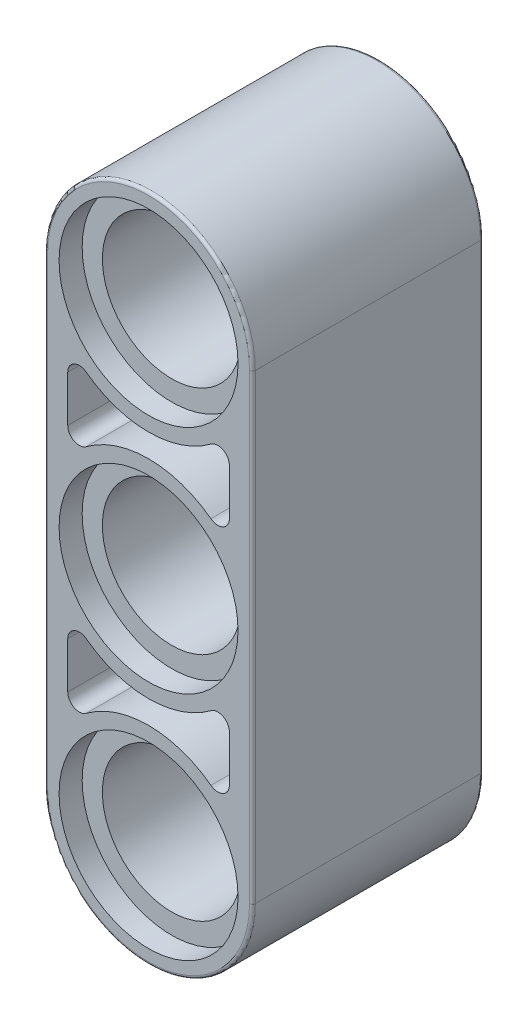
from build123d import *

# Parameters (mm, degrees)
BOSS_EXTRUDE1_DEPTH = 8
CUT_EXTRUDE2_DEPTH  = 3.1
CUT_EXTRUDE4_DEPTH  = 3.1
CUT_EXTRUDE6_DEPTH  = 3.1
CUT_EXTRUDE7_DEPTH  = 3.1
FILLET1_R           = 0.1


with BuildPart() as part:
    # Sketch1 → Boss-Extrude1 (new body)
    with BuildSketch(Plane.XY.offset(4)):
        with BuildLine():
            Line((-3.6, 0), (-3.6, -16))
            ThreePointArc((-3.6, -16), (0, -19.6), (3.6, -16))
            Line((3.6, -16), (3.6, 0))
            ThreePointArc((3.6, 0), (0, 3.6), (-3.6, 0))
        make_face()
    extrude(amount=-BOSS_EXTRUDE1_DEPTH)

    # Sketch3 → Cut-Extrude2 (cut)
    with BuildSketch(Plane.XY.offset(4)):
        with BuildLine():
            Line((2.8, -4.8), (2.8, -3.2))
            ThreePointArc((2.8, -3.2), (2.578885438, -2.842229124), (2.16, -2.88))
            ThreePointArc((2.16, -2.88), (0, -3.6), (-2.16, -2.88))
            ThreePointArc((-2.16, -2.88), (-2.578885438, -2.842229124), (-2.8, -3.2))
            Line((-2.8, -3.2), (-2.8, -4.8))
            ThreePointArc((-2.8, -4.8), (-2.578885438, -5.157770876), (-2.16, -5.12))
            ThreePointArc((-2.16, -5.12), (0, -4.4), (2.16, -5.12))
            ThreePointArc((2.16, -5.12), (2.578885438, -5.157770876), (2.8, -4.8))
        make_face()
    extrude(amount=-CUT_EXTRUDE2_DEPTH, mode=Mode.SUBTRACT)

    # Sketch5 → Cut-Extrude4 (cut)
    with BuildSketch(Plane.XY.offset(4)):
        with BuildLine():
            Line((2.8, -12.8), (2.8, -11.2))
            ThreePointArc((2.8, -11.2), (2.578885438, -10.842229124), (2.16, -10.88))
            ThreePointArc((2.16, -10.88), (0, -11.6), (-2.16, -10.88))
            ThreePointArc((-2.16, -10.88), (-2.578885438, -10.842229124), (-2.8, -11.2))
            Line((-2.8, -11.2), (-2.8, -12.8))
            ThreePointArc((-2.8, -12.8), (-2.578885438, -13.157770876), (-2.16, -13.12))
            ThreePointArc((-2.16, -13.12), (0, -12.4), (2.16, -13.12))
            ThreePointArc((2.16, -13.12), (2.578885438, -13.157770876), (2.8, -12.8))
        make_face()
    extrude(amount=-CUT_EXTRUDE4_DEPTH, mode=Mode.SUBTRACT)

    # Sketch7 → Cut-Extrude6 (cut)
    with BuildSketch(Plane(origin=(0, 0, -4), x_dir=(-1, 0, 0), z_dir=(0, 0, -1))):
        with BuildLine():
            Line((2.8, -4.8), (2.8, -3.2))
            ThreePointArc((2.8, -3.2), (2.578885438, -2.842229124), (2.16, -2.88))
            ThreePointArc((2.16, -2.88), (0, -3.6), (-2.16, -2.88))
            ThreePointArc((-2.16, -2.88), (-2.578885438, -2.842229124), (-2.8, -3.2))
            Line((-2.8, -3.2), (-2.8, -4.8))
            ThreePointArc((-2.8, -4.8), (-2.578885438, -5.157770876), (-2.16, -5.12))
            ThreePointArc((-2.16, -5.12), (0, -4.4), (2.16, -5.12))
            ThreePointArc((2.16, -5.12), (2.578885438, -5.157770876), (2.8, -4.8))
        make_face()
    extrude(amount=-CUT_EXTRUDE6_DEPTH, mode=Mode.SUBTRACT)

    # Sketch8 → Cut-Extrude7 (cut)
    with BuildSketch(Plane(origin=(0, 0, -4), x_dir=(-1, 0, 0), z_dir=(0, 0, -1))):
        with BuildLine():
            Line((-2.8, -11.2), (-2.8, -12.8))
            ThreePointArc((-2.8, -12.8), (-2.578885438, -13.157770876), (-2.16, -13.12))
            ThreePointArc((-2.16, -13.12), (0, -12.4), (2.16, -13.12))
            ThreePointArc((2.16, -13.12), (2.578885438, -13.157770876), (2.8, -12.8))
            Line((2.8, -12.8), (2.8, -11.2))
            ThreePointArc((2.8, -11.2), (2.578885438, -10.842229124), (2.16, -10.88))
            ThreePointArc((2.16, -10.88), (0, -11.6), (-2.16, -10.88))
            ThreePointArc((-2.16, -10.88), (-2.578885438, -10.842229124), (-2.8, -11.2))
        make_face()
    extrude(amount=-CUT_EXTRUDE7_DEPTH, mode=Mode.SUBTRACT)

    # Sketch10 → Cut-Revolve1 (revolve, cut)
    with BuildSketch(Plane(origin=(0, -16, 0), x_dir=(1, 0, 0), z_dir=(0, 1, 0))):
        Polygon((3.1, 4), (0, 4), (0, -4), (3.1, -4), (3.1, -3.2), (2.4, -3.2), (2.4, 3.2), (3.1, 3.2), align=None)
    revolve(axis=Axis((0, -16, -4), (0, 0, 1)), mode=Mode.SUBTRACT)

    # Sketch12 → Cut-Revolve3 (revolve, cut)
    with BuildSketch(Plane(origin=(0, -8, 0), x_dir=(1, 0, 0), z_dir=(0, 1, 0))):
        Polygon((3.1, 4), (0, 4), (0, -4), (3.1, -4), (3.1, -3.2), (2.4, -3.2), (2.4, 3.2), (3.1, 3.2), align=None)
    revolve(axis=Axis((0, -8, -4), (0, 0, 1)), mode=Mode.SUBTRACT)

    # Sketch13 → Cut-Revolve4 (revolve, cut)
    with BuildSketch(Plane(origin=(0, 0, 0), x_dir=(1, 0, 0), z_dir=(0, 1, 0))):
        Polygon((3.1, 4), (0, 4), (0, -4), (3.1, -4), (3.1, -3.2), (2.4, -3.2), (2.4, 3.2), (3.1, 3.2), align=None)
    revolve(axis=Axis((0, 0, -4), (0, 0, 1)), mode=Mode.SUBTRACT)

    # Fillet1
    fillet1_edges = [part.edges().sort_by_distance(p)[0] for p in [
        (0, -19.6, -4),
        (3.6, -8, -4),
        (0, 3.6, -4),
        (3.6, -8, 4),
        (0, -19.6, 4),
        (-3.6, -8, 4),
        (0, 3.6, 4),
        (-3.6, -8, -4),
    ]]
    fillet(fillet1_edges, radius=FILLET1_R)


solid = part.part
